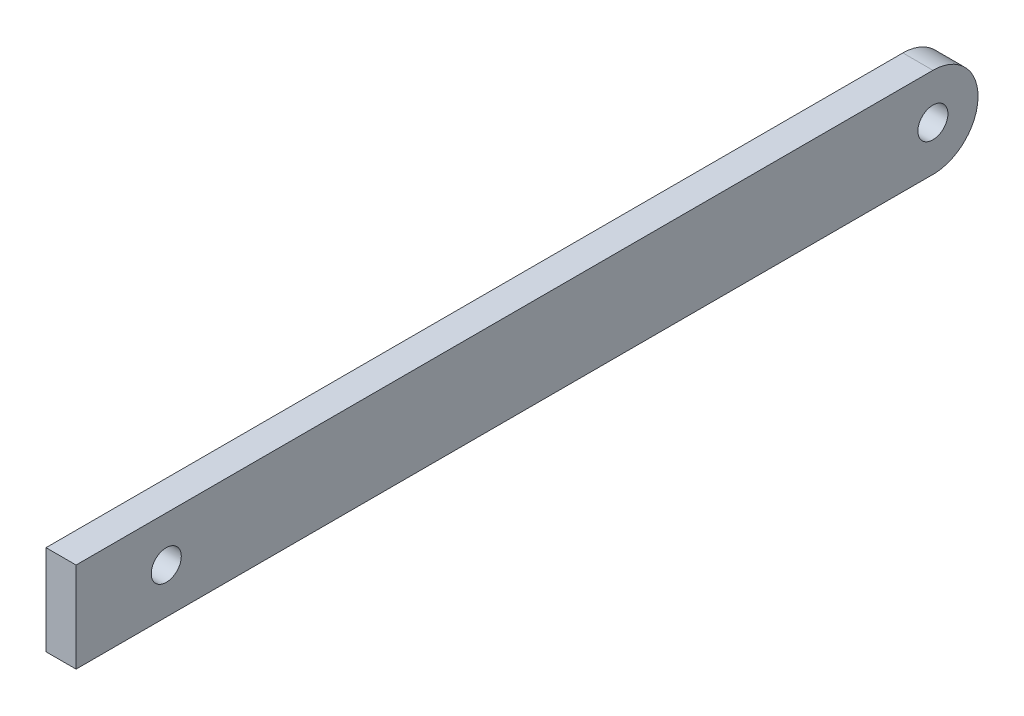
from build123d import *

# Parameters (mm, degrees)
SKETCH_1_W          = 10
SKETCH_1_H          = 300
EXTRUDE_2_DEPTH     = 30
SKETCH_3_R          = 5
CUT_EXTRUDE_3_DEPTH = 30
SKETCH_4_R          = 5
CUT_EXTRUDE_4_DEPTH = 10


with BuildPart() as part:
    # Эскиз1 → Бобышка-Вытянуть2 (new body)
    with BuildSketch(Plane(origin=(0, 0, 0), x_dir=(1, 0, 0), z_dir=(0, 1, 0))):
        with Locations((0.774647887, -135.809859155)):
            Rectangle(SKETCH_1_W, SKETCH_1_H)
    extrude(amount=EXTRUDE_2_DEPTH)

    # Эскиз3 → Вырез-Вытянуть3 (cut)
    with BuildSketch(Plane(origin=(5.774647887, 0, 0), x_dir=(0, 0, -1), z_dir=(1, 0, 0))):
        with BuildLine():
            ThreePointArc((-0.809859155, 30), (9.797423551, 25.599339913), (14.190140845, 14.988765453))
            Line((14.190140845, 14.988765453), (14.190140845, 30))
            Line((14.190140845, 30), (-0.809859155, 30))
        make_face()
        with BuildLine():
            Line((0, 0), (14.190140845, 0))
            Line((14.190140845, 0), (14.190140845, 14.988765453))
            ThreePointArc((14.190140845, 14.988765453), (10.079887974, 4.668600871), (0, 0))
        make_face()
        with Locations((-0.821097954, 14.988765408)):
            Circle(SKETCH_3_R)
    extrude(amount=-CUT_EXTRUDE_3_DEPTH, mode=Mode.SUBTRACT)

    # Эскиз4 → Вырез-Вытянуть4 (cut)
    with BuildSketch(Plane(origin=(5.774647887, 0, 0), x_dir=(0, 0, -1), z_dir=(1, 0, 0))):
        with Locations((-255.809859155, 15)):
            Circle(SKETCH_4_R)
    extrude(amount=-CUT_EXTRUDE_4_DEPTH, mode=Mode.SUBTRACT)


solid = part.part
